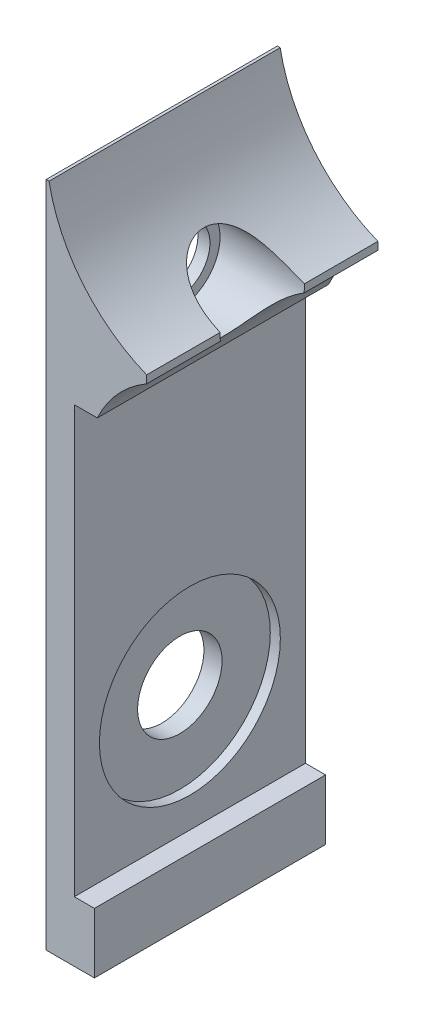
from build123d import *

# Parameters (mm, degrees)
SALIENTE_EXTRUIR1_DEPTH = 11.5
CORTAR_EXTRUIR1_START   = -5
CROQUIS2_R              = 2.1
CORTAR_EXTRUIR1_DEPTH   = 5
CROQUIS3_R              = 4.5
CORTAR_EXTRUIR2_DEPTH   = 0.5
CROQUIS4_R              = 3
CORTAR_EXTRUIR3_DEPTH   = 0.2
CROQUIS5_R              = 2.1
CROQUIS5_R_2            = 1.6
SALIENTE_EXTRUIR2_DEPTH = 0.6
CORTAR_EXTRUIR5_DEPTH   = 11.5


with BuildPart() as part:
    # Croquis1 → Saliente-Extruir1 (new body)
    with BuildSketch(Plane.XY):
        Polygon((-89.253382482, -13.336480186), (-89.253382482, 19.863519814), (-87.853382482, 19.863519814), (-87.853382482, 16.863519814), (-84.253382482, 16.863519814), (-84.253382482, 10.863519814), (-87.853382482, 10.863519814), (-87.853382482, -10.336480186), (-86.853382482, -10.336480186), (-86.853382482, -13.336480186), align=None)
    extrude(amount=SALIENTE_EXTRUIR1_DEPTH)

    # Croquis2 → Cortar-Extruir1 (cut)
    with BuildSketch(Plane(origin=(-84.253382482, 0, 0), x_dir=(0, 0, -1), z_dir=(1, 0, 0)).offset(CORTAR_EXTRUIR1_START)):
        with Locations((-5.75, 13.863519814)):
            Circle(CROQUIS2_R)
        with Locations((-5.75, -4.336480186)):
            Circle(CROQUIS2_R)
    extrude(amount=CORTAR_EXTRUIR1_DEPTH, mode=Mode.SUBTRACT)

    # Croquis3 → Cortar-Extruir2 (cut)
    with BuildSketch(Plane(origin=(-87.853382482, 0, 0), x_dir=(0, 0, -1), z_dir=(1, 0, 0))):
        with Locations((-5.75, -4.336480186)):
            Circle(CROQUIS3_R)
    extrude(amount=-CORTAR_EXTRUIR2_DEPTH, mode=Mode.SUBTRACT)

    # Croquis4 → Cortar-Extruir3 (cut)
    with BuildSketch(Plane.ZY.offset(89.253382482)):
        with Locations((5.75, 13.863519814)):
            Circle(CROQUIS4_R)
    extrude(amount=-CORTAR_EXTRUIR3_DEPTH, mode=Mode.SUBTRACT)

    # Croquis5 → Saliente-Extruir2 (add)
    with BuildSketch(Plane.ZY.offset(89.053382482)):
        with Locations((5.75, 13.863519814)):
            Circle(CROQUIS5_R)
        with Locations((5.75, 13.863519814)):
            Circle(CROQUIS5_R_2, mode=Mode.SUBTRACT)
    extrude(amount=-SALIENTE_EXTRUIR2_DEPTH)

    # Croquis6 → Cortar-Extruir5 (cut)
    with BuildSketch(Plane.XY.offset(11.5)):
        with BuildLine():
            ThreePointArc((-78.686236851, 13.786596737), (-81.253382482, 29.363519814), (-83.820528112, 13.786596737))
            ThreePointArc((-83.820528112, 13.786596737), (-81.253382482, 2.363519814), (-78.686236851, 13.786596737))
        make_face()
    extrude(amount=-CORTAR_EXTRUIR5_DEPTH, mode=Mode.SUBTRACT)


solid = part.part
